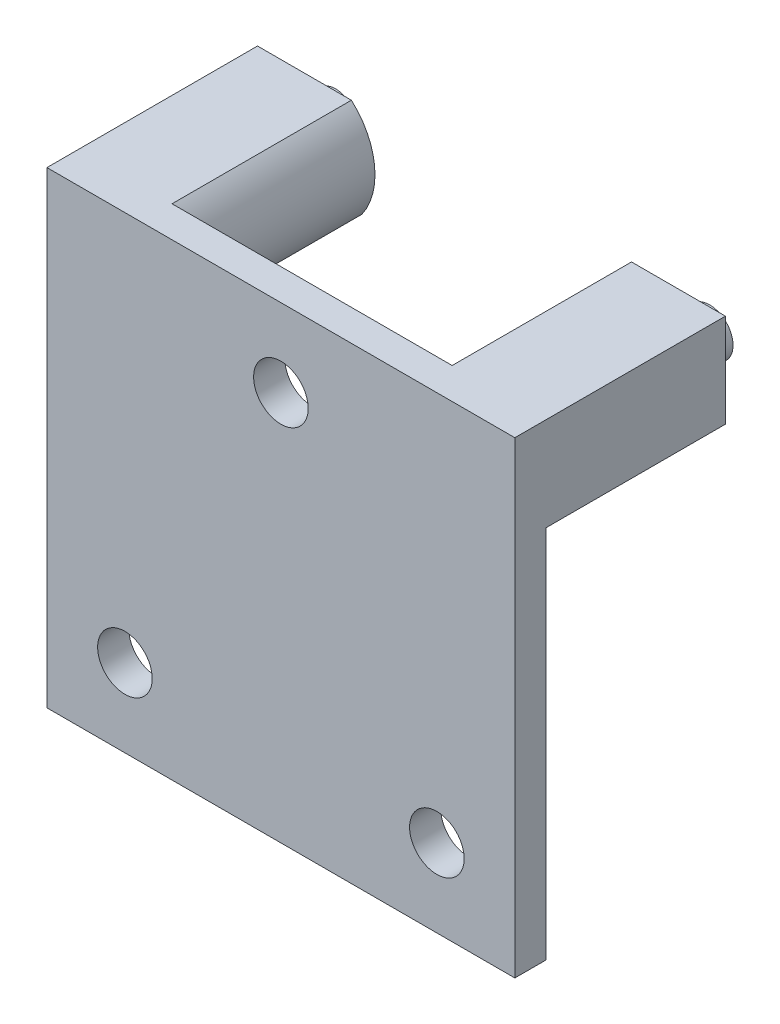
from build123d import *

# Parameters (mm, degrees)
SKETCH1_W           = 30
SKETCH1_H           = 30
BOSS_EXTRUDE1_DEPTH = 2
BOSS_EXTRUDE3_DEPTH = 11.5
SKETCH3_R           = 1.5
BOSS_EXTRUDE4_DEPTH = 2
SKETCH4_R           = 5
SKETCH4_R_2         = 3.5
BOSS_EXTRUDE5_DEPTH = 5
SKETCH5_R           = 1.75
CUT_EXTRUDE1_DEPTH  = 3


with BuildPart() as part:
    # Sketch1 → Boss-Extrude1 (new body)
    with BuildSketch(Plane.XY):
        with Locations((14.990081794, 9.125005221)):
            Rectangle(SKETCH1_W, SKETCH1_H)
    extrude(amount=BOSS_EXTRUDE1_DEPTH)

    # Sketch2 → Boss-Extrude3 (add)
    with BuildSketch(Plane(origin=(0, 0, 0), x_dir=(-1, 0, 0), z_dir=(0, 0, -1))):
        with BuildLine():
            Line((0.009918206, 24.125005221), (0.009918206, 18.125005221))
            Line((0.009918206, 18.125005221), (-6.682350101, 18.125005221))
            ThreePointArc((-6.682350101, 18.125005221), (-7.494065902, 21.253655407), (-6.009921446, 24.125005221))
            Line((-6.009921446, 24.125005221), (0.009918206, 24.125005221))
        make_face()
    boss_extrude3 = extrude(amount=BOSS_EXTRUDE3_DEPTH)

    # Sketch3 → Boss-Extrude4 (add)
    with BuildSketch(Plane(origin=(0, 0, -11.5), x_dir=(-1, 0, 0), z_dir=(0, 0, -1))):
        with Locations((-3.00000162, 20.74999914)):
            Circle(SKETCH3_R)
    boss_extrude4 = extrude(amount=BOSS_EXTRUDE4_DEPTH)

    # Mirror1: Boss-Extrude3, Boss-Extrude4 across plane
    add(boss_extrude3.mirror(Plane(origin=(14.990081794, 0, 0), x_dir=(0, 0, 1), z_dir=(1, 0, 0))))
    add(boss_extrude4.mirror(Plane(origin=(14.990081794, 0, 0), x_dir=(0, 0, 1), z_dir=(1, 0, 0))))

    # Sketch4 → Boss-Extrude5 (add)
    with BuildSketch(Plane(origin=(0, 0, 0), x_dir=(-1, 0, 0), z_dir=(0, 0, -1))):
        with Locations((-13.707999, 3.46499688)):
            Circle(SKETCH4_R)
        with Locations((-13.707999, 3.46499688)):
            Circle(SKETCH4_R_2, mode=Mode.SUBTRACT)
    extrude(amount=BOSS_EXTRUDE5_DEPTH)

    # Sketch5 → Cut-Extrude1 (cut, through all)
    with BuildSketch(Plane(origin=(0, 0, 0), x_dir=(-1, 0, 0), z_dir=(0, 0, -1))):
        with Locations((-24.990081794, -0.874994779)):
            Circle(SKETCH5_R)
        with Locations((-4.990081794, -0.874994779)):
            Circle(SKETCH5_R)
        with Locations((-14.990081794, 19.125005221)):
            Circle(SKETCH5_R)
    extrude(amount=-CUT_EXTRUDE1_DEPTH, mode=Mode.SUBTRACT)


solid = part.part
